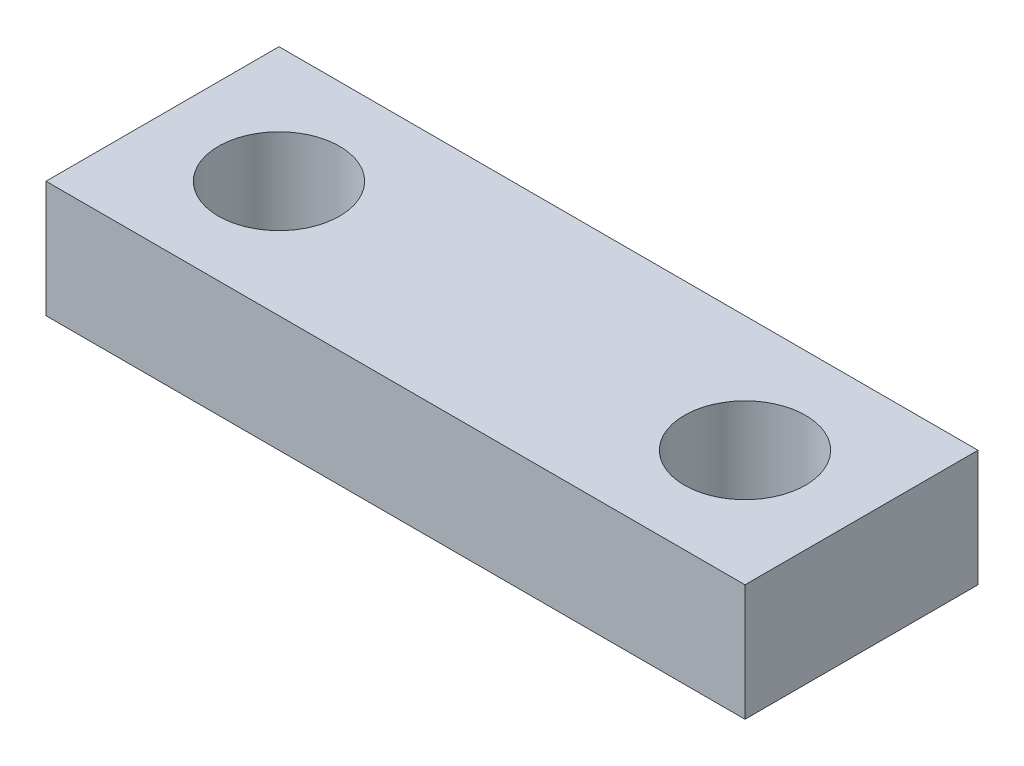
from build123d import *

# Parameters (mm, degrees)
SKETCH1_W           = 38.1
SKETCH1_H           = 12.7
SKETCH1_R           = 3.302
BOSS_EXTRUDE1_DEPTH = 6.35


with BuildPart() as part:
    # Sketch1 → Boss-Extrude1 (new body)
    with BuildSketch(Plane(origin=(0, 0, 0), x_dir=(1, 0, 0), z_dir=(0, 1, 0))):
        with Locations((19.05, 6.35)):
            Rectangle(SKETCH1_W, SKETCH1_H)
        with Locations((6.35, 6.35)):
            Circle(SKETCH1_R, mode=Mode.SUBTRACT)
        with Locations((31.75, 6.35)):
            Circle(SKETCH1_R, mode=Mode.SUBTRACT)
    extrude(amount=BOSS_EXTRUDE1_DEPTH)


solid = part.part
